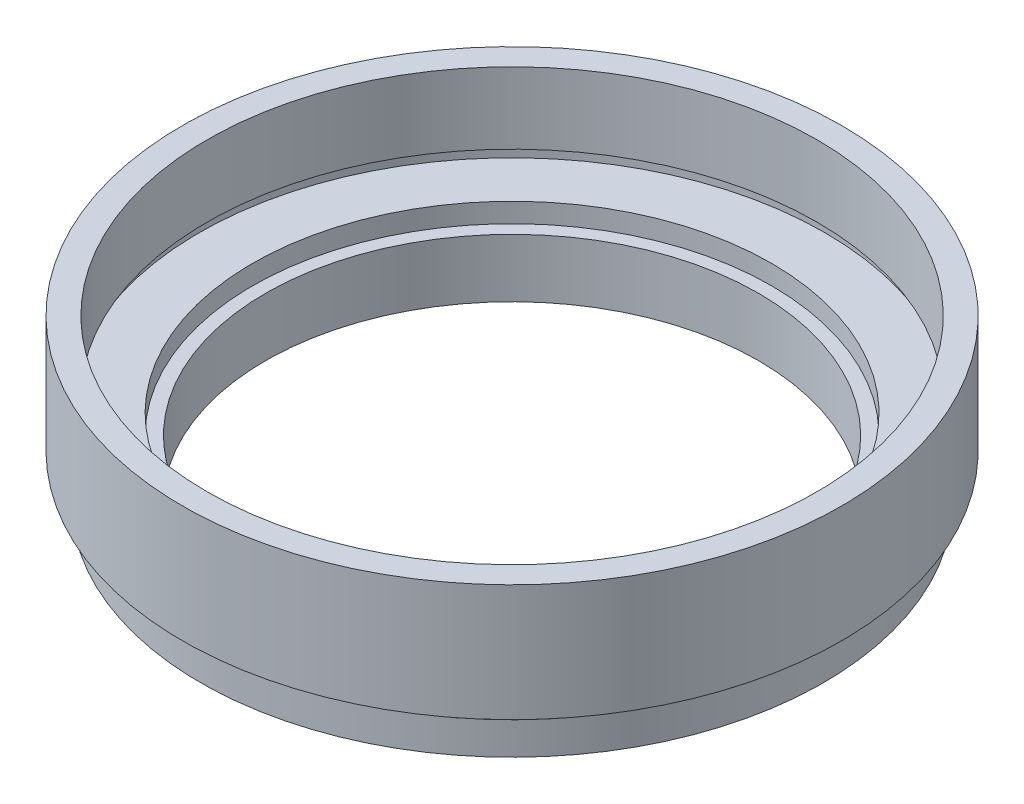
from build123d import *


with BuildPart() as part:
    # 草图1 → 旋转1 (revolve)
    with BuildSketch(Plane.XY, mode=Mode.PRIVATE) as revolve_1_sk:
        Polygon((19, 0), (24, 0), (24, 2.5), (23.5, 2.5), (23.5, 3.5), (25.4, 3.5), (25.4, 12.5), (23.5, 12.5), (23.5, 7), (24.1, 7), (24.1, 6), (20, 6), (20, 4.5), (19, 4.5), align=None)
    revolve(revolve_1_sk.sketch.rotate(Axis((0, 0, 0), (0, 1, 0)), 90), axis=Axis((0, 0, 0), (0, 1, 0)))  # turned: the seam where the file's is


solid = part.part
